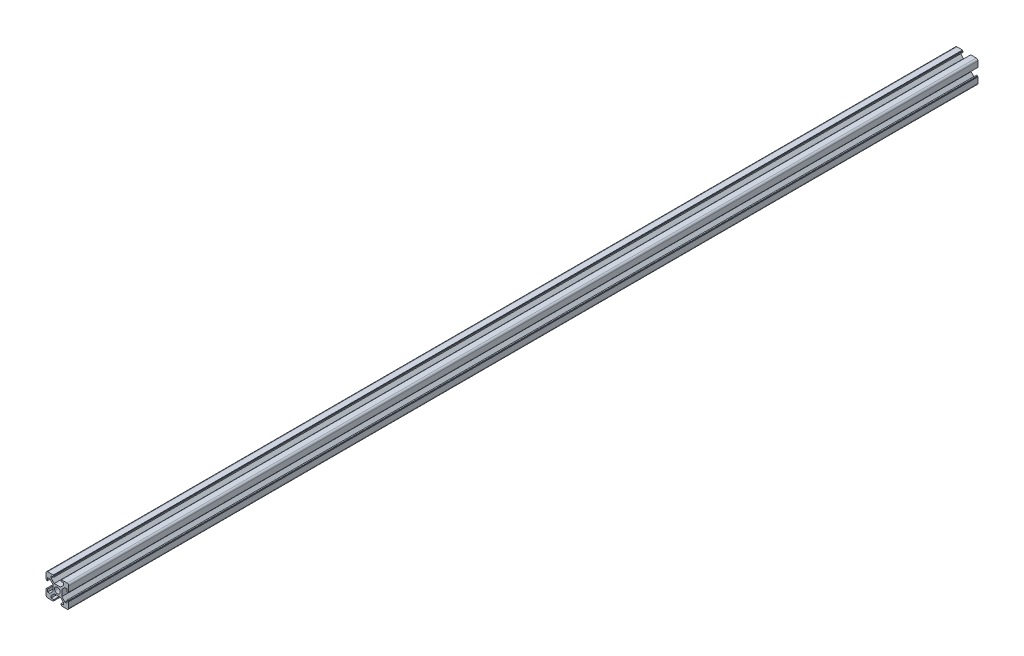
from build123d import *

# Parameters (mm, degrees)
SKETCH_1_R      = 2.5
EXTRUDE_1_DEPTH = 800


with BuildPart() as part:
    # 草图1 → 凸台-拉伸1 (new body)
    with BuildSketch(Plane.XY):
        with BuildLine():
            Line((-3.6, 10), (-3.6, 9.5))
            Line((-3.6, 9.5), (-3.1, 9.5))
            Line((-3.1, 9.5), (-3.1, 8.5))
            Line((-3.1, 8.5), (-5.5, 8.5))
            Line((-5.5, 8.5), (-5.5, 6.65))
            Line((-5.5, 6.65), (-2.75, 3.9))
            Line((-2.75, 3.9), (2.75, 3.9))
            Line((2.75, 3.9), (5.5, 6.65))
            Line((5.5, 6.65), (5.5, 8.5))
            Line((5.5, 8.5), (3.1, 8.5))
            Line((3.1, 8.5), (3.1, 9.5))
            Line((3.1, 9.5), (3.6, 9.5))
            Line((3.6, 9.5), (3.6, 10))
            Line((3.6, 10), (8.5, 10))
            ThreePointArc((8.5, 10), (9.560660172, 9.560660172), (10, 8.5))
            Line((10, 8.5), (10, 3.6))
            Line((10, 3.6), (9.5, 3.6))
            Line((9.5, 3.6), (9.5, 3.1))
            Line((9.5, 3.1), (8.5, 3.1))
            Line((8.5, 3.1), (8.5, 5.5))
            Line((8.5, 5.5), (6.65, 5.5))
            Line((6.65, 5.5), (3.9, 2.75))
            Line((3.9, 2.75), (3.9, -2.75))
            Line((3.9, -2.75), (6.65, -5.5))
            Line((6.65, -5.5), (8.5, -5.5))
            Line((8.5, -5.5), (8.5, -3.1))
            Line((8.5, -3.1), (9.5, -3.1))
            Line((9.5, -3.1), (9.5, -3.6))
            Line((9.5, -3.6), (10, -3.6))
            Line((10, -3.6), (10, -8.5))
            ThreePointArc((10, -8.5), (9.560660172, -9.560660172), (8.5, -10))
            Line((8.5, -10), (3.6, -10))
            Line((3.6, -10), (3.6, -9.5))
            Line((3.6, -9.5), (3.1, -9.5))
            Line((3.1, -9.5), (3.1, -8.5))
            Line((3.1, -8.5), (5.5, -8.5))
            Line((5.5, -8.5), (5.5, -6.65))
            Line((5.5, -6.65), (2.75, -3.9))
            Line((2.75, -3.9), (-2.75, -3.9))
            Line((-2.75, -3.9), (-5.5, -6.65))
            Line((-5.5, -6.65), (-5.5, -8.5))
            Line((-5.5, -8.5), (-3.1, -8.5))
            Line((-3.1, -8.5), (-3.1, -9.5))
            Line((-3.1, -9.5), (-3.6, -9.5))
            Line((-3.6, -9.5), (-3.6, -10))
            Line((-3.6, -10), (-8.5, -10))
            ThreePointArc((-8.5, -10), (-9.560660172, -9.560660172), (-10, -8.5))
            Line((-10, -8.5), (-10, -3.6))
            Line((-10, -3.6), (-9.5, -3.6))
            Line((-9.5, -3.6), (-9.5, -3.1))
            Line((-9.5, -3.1), (-8.5, -3.1))
            Line((-8.5, -3.1), (-8.5, -5.5))
            Line((-8.5, -5.5), (-6.65, -5.5))
            Line((-6.65, -5.5), (-3.9, -2.75))
            Line((-3.9, -2.75), (-3.9, 2.75))
            Line((-3.9, 2.75), (-6.65, 5.5))
            Line((-6.65, 5.5), (-8.5, 5.5))
            Line((-8.5, 5.5), (-8.5, 3.1))
            Line((-8.5, 3.1), (-9.5, 3.1))
            Line((-9.5, 3.1), (-9.5, 3.6))
            Line((-9.5, 3.6), (-10, 3.6))
            Line((-10, 3.6), (-10, 8.5))
            ThreePointArc((-10, 8.5), (-9.560660172, 9.560660172), (-8.5, 10))
            Line((-8.5, 10), (-3.6, 10))
        make_face()
        Circle(SKETCH_1_R, mode=Mode.SUBTRACT)
    extrude(amount=EXTRUDE_1_DEPTH)


solid = part.part
